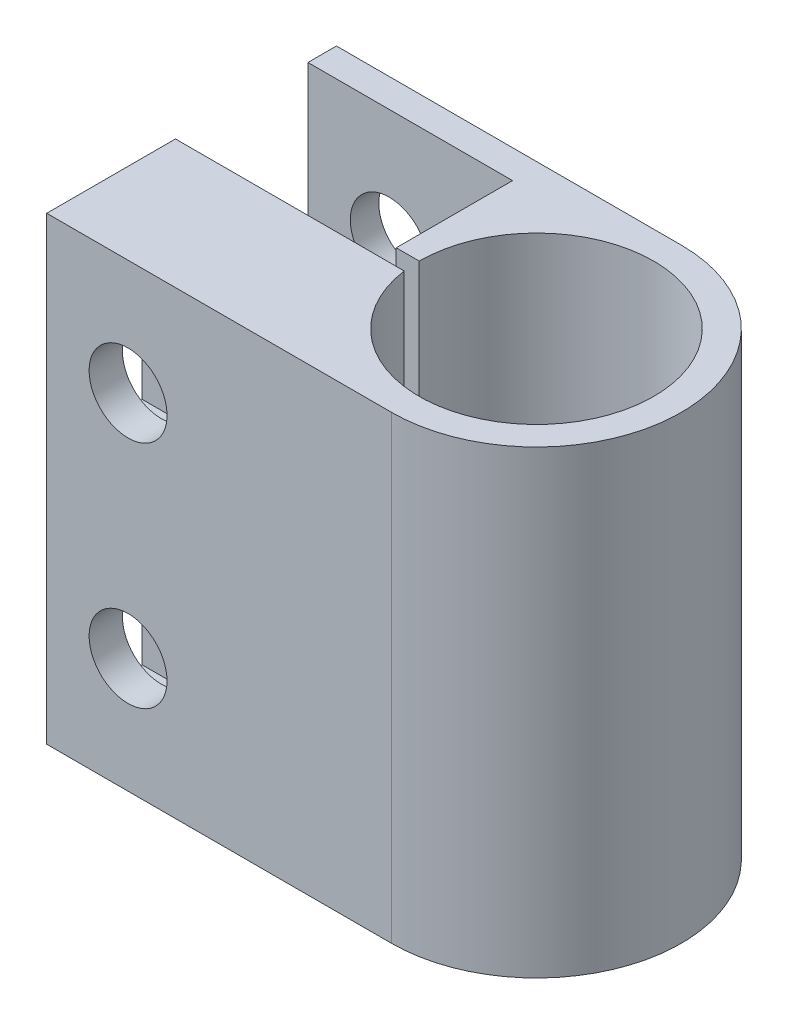
from build123d import *

# Parameters (mm, degrees)
BOSS_EXTRUDE2_DEPTH = 25.4
SKETCH10_R          = 2.15265
CUT_EXTRUDE1_DEPTH  = 17.002
CUT_EXTRUDE3_DEPTH  = 3.429
CUT_EXTRUDE4_START  = -4.492625
SKETCH12_W          = 3.429
SKETCH12_H          = 10.375273012
CUT_EXTRUDE4_DEPTH  = 4.492625


with BuildPart() as part:
    # Sketch9 → Boss-Extrude2 (new body)
    with BuildSketch(Plane(origin=(0, 0, 0), x_dir=(1, 0, 0), z_dir=(0, 1, 0))):
        with BuildLine():
            Line((46.02381262, 54.02481262), (26.97381262, 54.02481262))
            Line((26.97381262, 54.02481262), (26.97381262, 52.45001262))
            Line((26.97381262, 52.45001262), (38.27681262, 52.45001262))
            Line((38.27681262, 52.45001262), (38.27681262, 46.02381262))
            Line((38.27681262, 46.02381262), (39.54681262, 46.02381262))
            ThreePointArc((39.54681262, 46.02381262), (52.485469477, 46.469368082), (39.608112503, 45.13481262))
            Line((39.608112503, 45.13481262), (26.97381262, 45.13481262))
            Line((26.97381262, 45.13481262), (26.97381262, 38.02281262))
            Line((26.97381262, 38.02281262), (46.02381262, 38.02281262))
            ThreePointArc((46.02381262, 38.02281262), (54.02481262, 46.02381262), (46.02381262, 54.02481262))
        make_face()
    extrude(amount=BOSS_EXTRUDE2_DEPTH)

    # Sketch10 → Cut-Extrude1 (cut, through all)
    with BuildSketch(Plane(origin=(0, 0, -38.02281262), x_dir=(-1, 0, 0), z_dir=(0, 0, -1))):
        with Locations((-31.46643762, 19.05)):
            Circle(SKETCH10_R)
        with Locations((-31.46643762, 6.35)):
            Circle(SKETCH10_R)
    extrude(amount=CUT_EXTRUDE1_DEPTH, mode=Mode.SUBTRACT)

    # Sketch11 → Cut-Extrude3 (cut)
    with BuildSketch(Plane(origin=(0, 0, -39.86431262), x_dir=(-1, 0, 0), z_dir=(0, 0, -1))):
        Polygon((-35.95906262, 8.943818253), (-31.46643762, 11.537636506), (-26.97381262, 8.943818253), (-26.97381262, 3.756181747), (-31.46643762, 1.162363494), (-35.95906262, 3.756181747), align=None)
        Polygon((-26.97381262, 16.456181747), (-26.97381262, 21.643818253), (-31.46643762, 24.237636506), (-35.95906262, 21.643818253), (-35.95906262, 16.456181747), (-31.46643762, 13.862363494), align=None)
    extrude(amount=CUT_EXTRUDE3_DEPTH, mode=Mode.SUBTRACT)

    # Sketch12 → Cut-Extrude4 (cut)
    with BuildSketch(Plane.ZY.offset(-26.97381262).offset(CUT_EXTRUDE4_START)):
        with Locations((-41.57881262, 6.35)):
            Rectangle(SKETCH12_W, SKETCH12_H)
        with Locations((-41.57881262, 19.05)):
            Rectangle(SKETCH12_W, SKETCH12_H)
    extrude(amount=CUT_EXTRUDE4_DEPTH, mode=Mode.SUBTRACT)


solid = part.part
